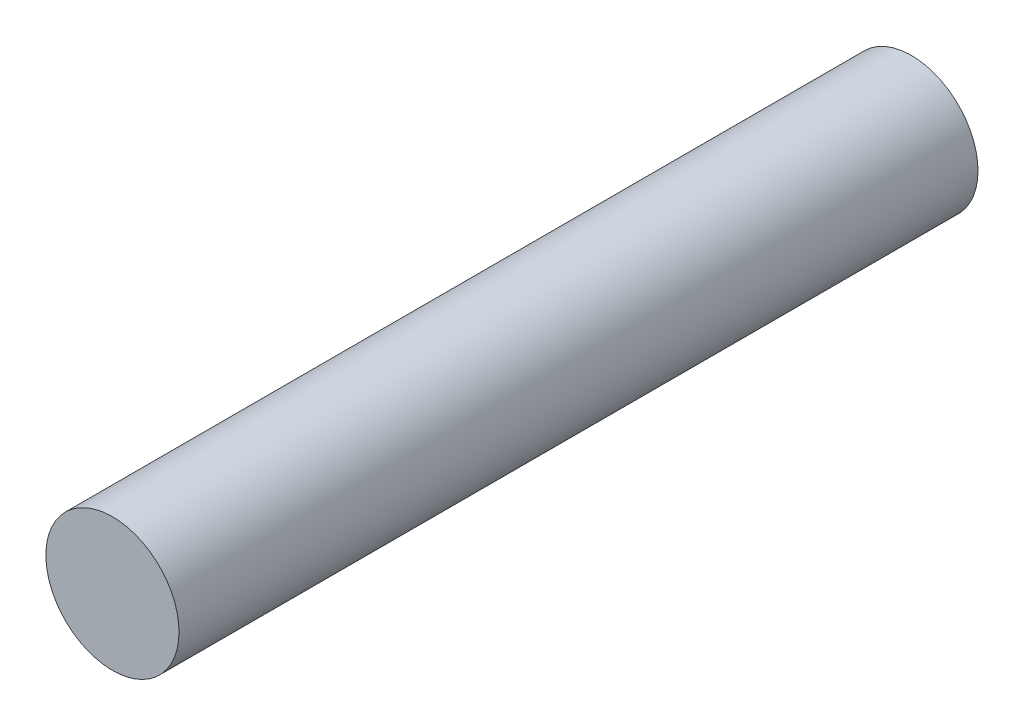
from build123d import *

# Parameters (mm, degrees)
SKETCH1_R           = 2.5
BOSS_EXTRUDE1_DEPTH = 30


with BuildPart() as part:
    # Sketch1 → Boss-Extrude1 (new body)
    with BuildSketch(Plane.XY.offset(15)):
        with Locations((-19, 30.428638458)):
            Circle(SKETCH1_R)
    extrude(amount=-BOSS_EXTRUDE1_DEPTH)


solid = part.part
